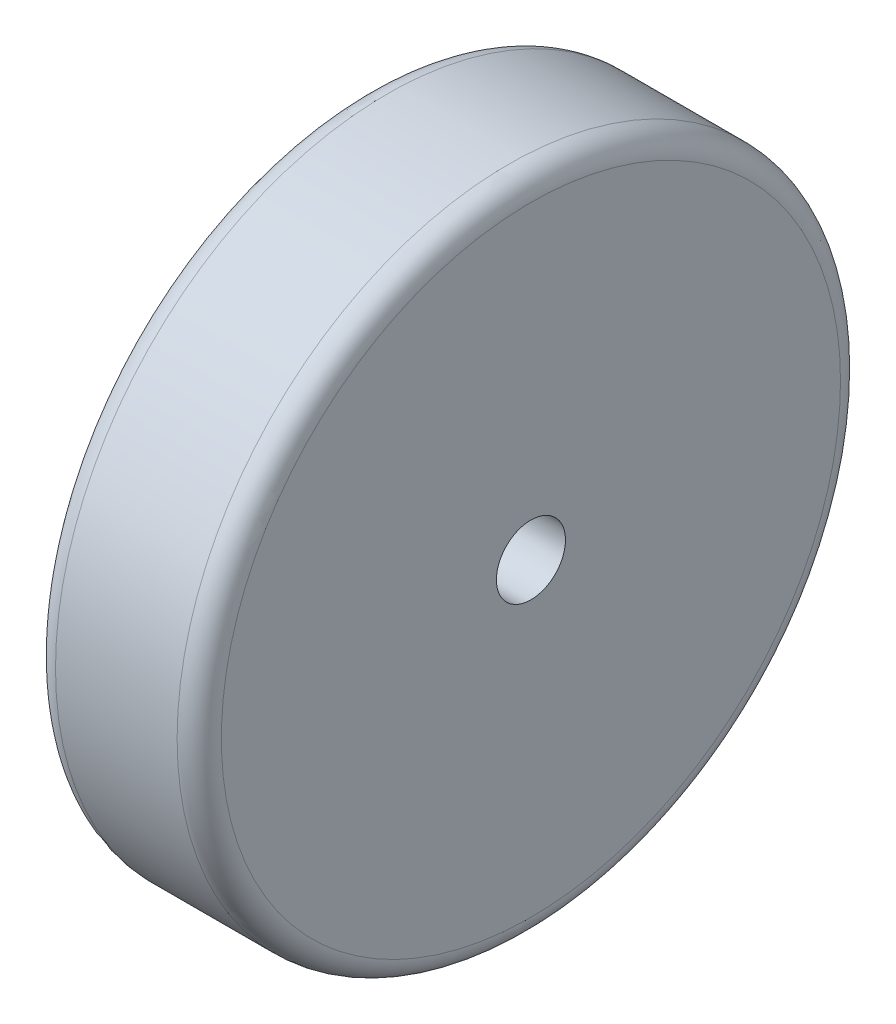
from build123d import *

# Parameters (mm, degrees)
SKETCH1_R           = 76.2
SKETCH1_R_2         = 7.9375
BOSS_EXTRUDE1_DEPTH = 38.1
FILLET1_R           = 5.08


with BuildPart() as part:
    # Sketch1 → Boss-Extrude1 (new body)
    with BuildSketch(Plane(origin=(0, 0, 0), x_dir=(0, 0, -1), z_dir=(1, 0, 0))):
        Circle(SKETCH1_R)
        Circle(SKETCH1_R_2, mode=Mode.SUBTRACT)
    extrude(amount=BOSS_EXTRUDE1_DEPTH)

    # Fillet1
    fillet1_edges = [part.edges().sort_by_distance(p)[0] for p in [
        (38.1, 0, 76.2),
        (0, 0, 76.2),
    ]]
    fillet(fillet1_edges, radius=FILLET1_R)


solid = part.part
